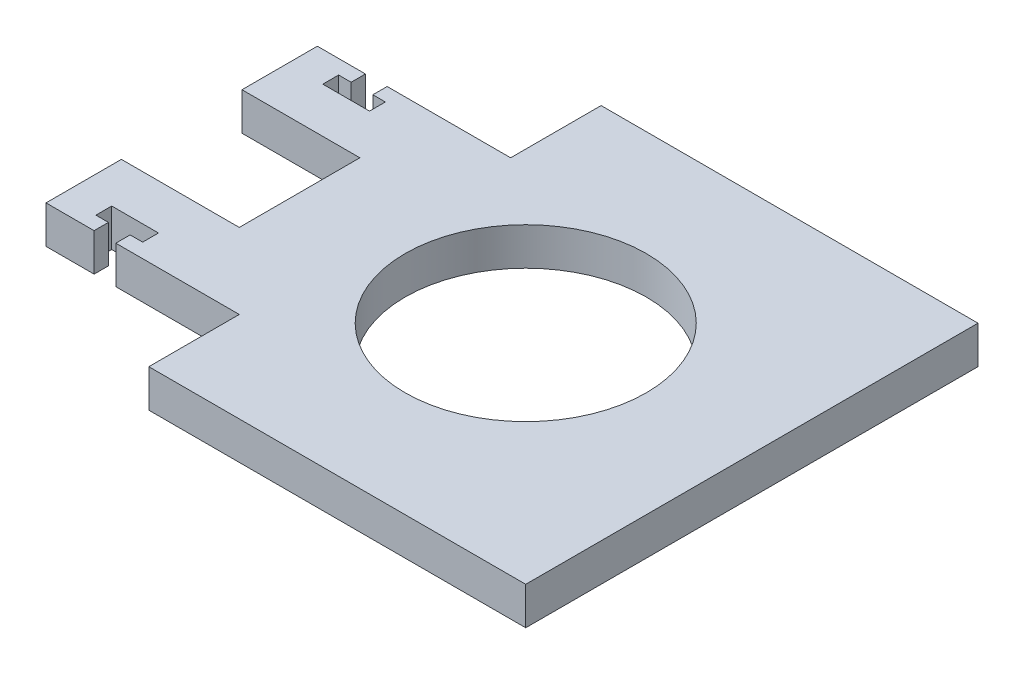
from build123d import *

# Parameters (mm, degrees)
SKETCH1_R           = 20.32
BOSS_EXTRUDE1_DEPTH = 6.35


with BuildPart() as part:
    # Sketch1 → Boss-Extrude1 (new body)
    with BuildSketch(Plane(origin=(0, 0, 0), x_dir=(1, 0, 0), z_dir=(0, 1, 0))):
        Polygon((-25.4, -38.1), (38.1, -38.1), (38.1, 38.1), (-25.4, 38.1), (-25.4, 22.86), (-38.1, 22.86), (-46.2026, 22.86), (-46.2026, 20.447), (-44.0944, 20.447), (-44.0944, 17.78), (-51.9684, 17.78), (-51.9684, 20.447), (-49.8602, 20.447), (-49.8602, 22.86), (-57.9628, 22.86), (-57.9628, 10.16), (-38.1, 10.16), (-38.1, -10.16), (-57.9628, -10.16), (-57.9628, -22.86), (-49.8602, -22.86), (-49.8602, -20.447), (-51.9684, -20.447), (-51.9684, -17.78), (-44.0944, -17.78), (-44.0944, -20.447), (-46.2026, -20.447), (-46.2026, -22.86), (-38.1, -22.86), (-25.4, -22.86), align=None)
        Circle(SKETCH1_R, mode=Mode.SUBTRACT)
    extrude(amount=-BOSS_EXTRUDE1_DEPTH)


solid = part.part
